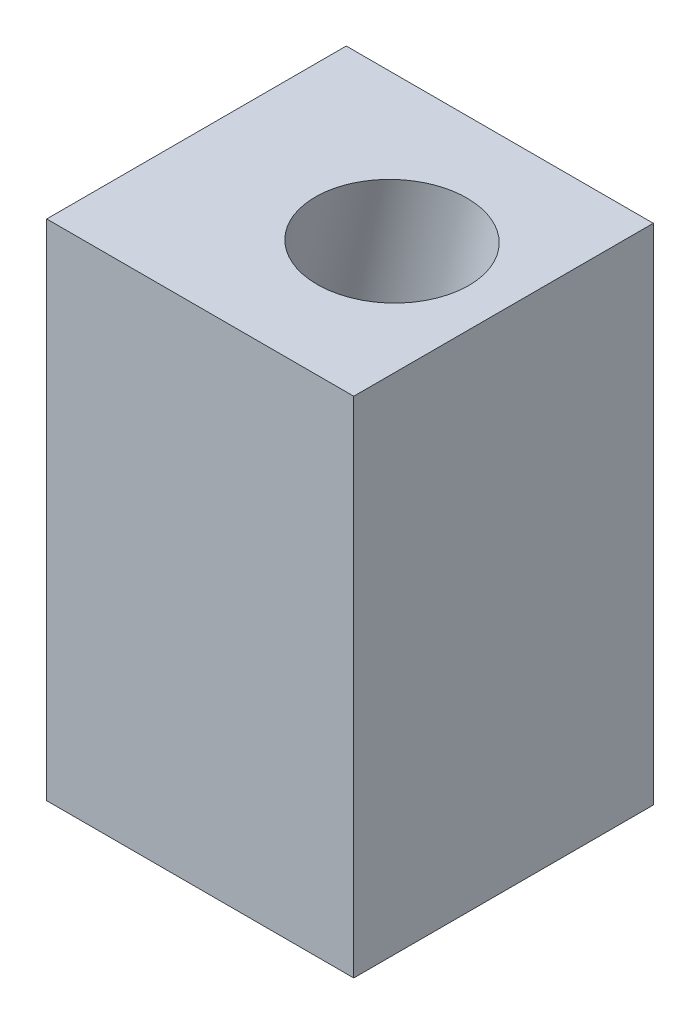
from build123d import *

# Parameters (mm, degrees)
SKETCH1_W           = 26.035
SKETCH1_H           = 42.7228
BOSS_EXTRUDE1_DEPTH = 25.4
SKETCH19_R          = 6.35
CUT_EXTRUDE1_DEPTH  = 31.75


with BuildPart() as part:
    # Sketch1 → Boss-Extrude1 (new body)
    with BuildSketch(Plane.XY):
        Rectangle(SKETCH1_W, SKETCH1_H)
    extrude(amount=BOSS_EXTRUDE1_DEPTH)

    # Sketch19 → Cut-Extrude1 (cut)
    with BuildSketch(Plane(origin=(5.123678059, 23.111418192, 0), x_dir=(-0.976296007, 0.216439614, 0), z_dir=(-0.216439614, -0.976296007, 0))):
        with Locations((1.439519896, -12.397187114)):
            Circle(SKETCH19_R)
    extrude(amount=CUT_EXTRUDE1_DEPTH, mode=Mode.SUBTRACT)


solid = part.part
